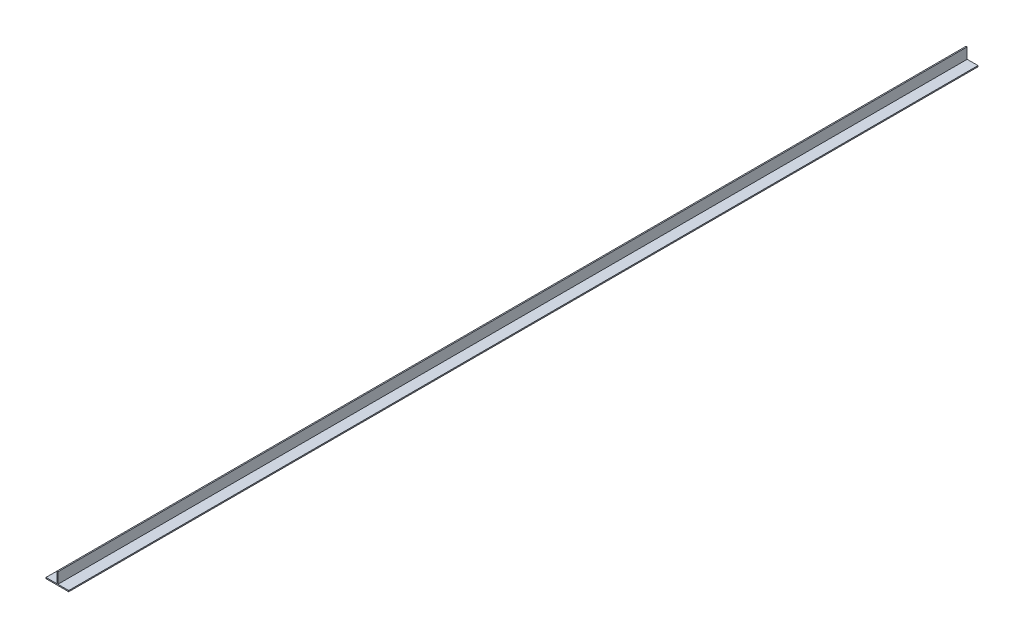
from build123d import *

# Parameters (mm, degrees)
SALIENTE_EXTRUIR1_DEPTH = 400


with BuildPart() as part:
    # Croquis1 → Saliente-Extruir1 (new body, symmetric)
    with BuildSketch(Plane.XY):
        Polygon((-10, 0), (-0.5, 0), (-0.5, 9.5), (0.5, 9.5), (0.5, 0), (10, 0), (10, -1), (-10, -1), align=None)
    extrude(amount=SALIENTE_EXTRUIR1_DEPTH, both=True)


solid = part.part
